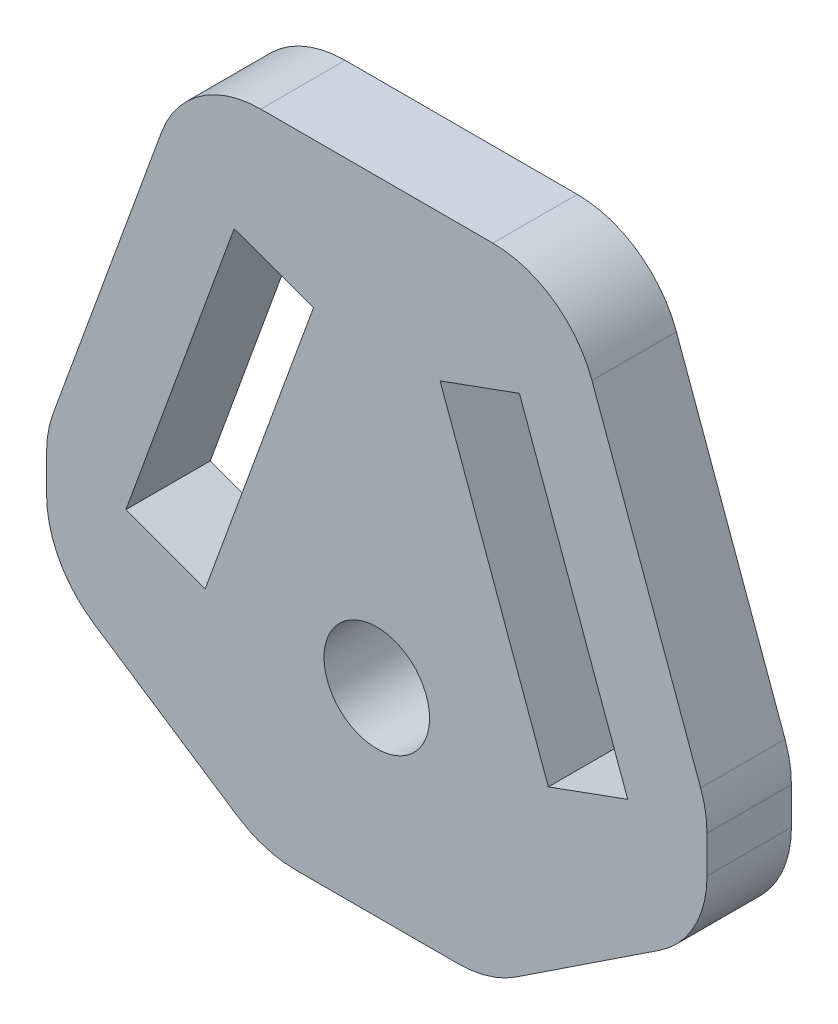
from build123d import *

# Parameters (mm, degrees)
SKETCH_1_R      = 2.5
EXTRUDE_1_DEPTH = 4
FILLET_1_R      = 5


with BuildPart() as part:
    # ｽｹｯﾁ1 → ﾎﾞｽ - 押し出し1 (new body)
    with BuildSketch(Plane.XY):
        Polygon((9.00034941, 21), (-9.00034941, 21), (-15.647843116, 2.736161147), (-15.647843116, -2.584727716), (-5.344155371, -9.396926208), (5.344155371, -9.396926208), (15.647843116, -2.584727716), (15.647843116, 2.736161147), align=None)
        Circle(SKETCH_1_R, mode=Mode.SUBTRACT)
        Polygon((-11.889072633, 1.368080573), (-6.758770483, 15.463469885), (-3, 14.095389312), (-8.13030215, 0), align=None, mode=Mode.SUBTRACT)
        Polygon((8.13030215, 0), (3, 14.095389312), (6.758770483, 15.463469885), (11.889072633, 1.368080573), align=None, mode=Mode.SUBTRACT)
    extrude(amount=EXTRUDE_1_DEPTH)

    # ﾌｨﾚｯﾄ1
    fillet_1_edges = [part.edges().sort_by_distance(p)[0] for p in [
        (-15.647843116, 2.736161147, 2),
        (-9.00034941, 21, 2),
        (9.00034941, 21, 2),
        (15.647843116, 2.736161147, 2),
        (15.647843116, -2.584727716, 2),
        (5.344155371, -9.396926208, 2),
        (-5.344155371, -9.396926208, 2),
        (-15.647843116, -2.584727716, 2),
    ]]
    fillet(fillet_1_edges, radius=FILLET_1_R)


solid = part.part
